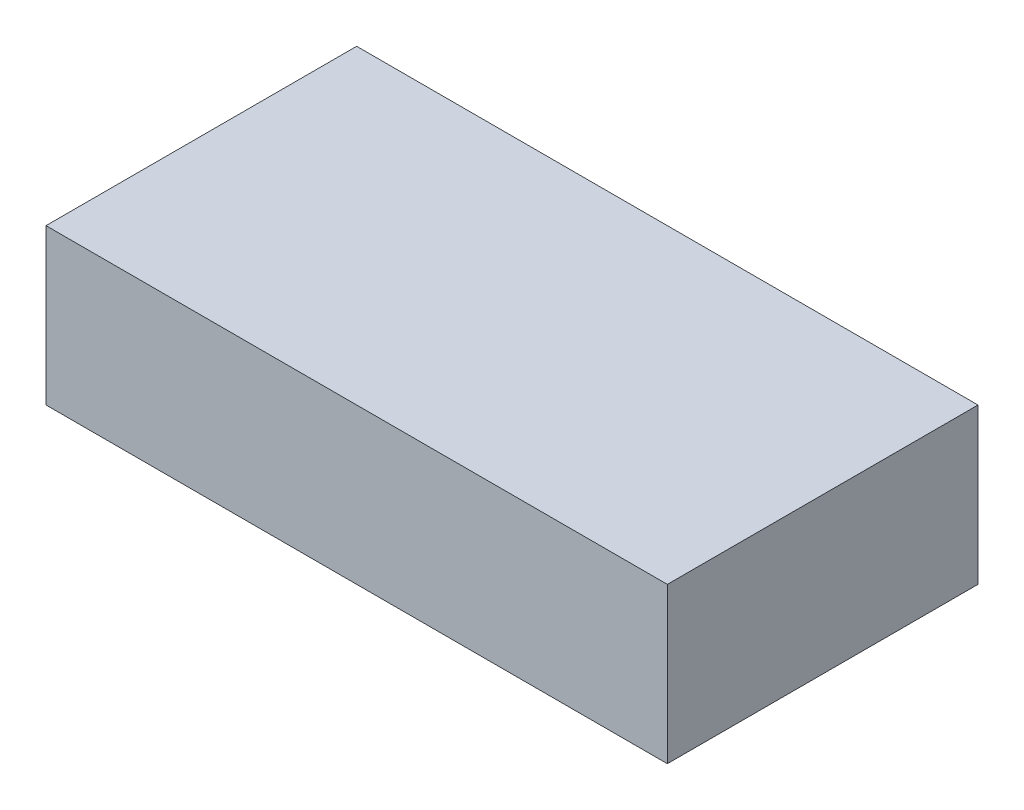
from build123d import *

# Parameters (mm, degrees)
SKETCH1_W           = 200
SKETCH1_H           = 100
BOSS_EXTRUDE1_DEPTH = 25


with BuildPart() as part:
    # Sketch1 → Boss-Extrude1 (new body, symmetric)
    with BuildSketch(Plane(origin=(0, 0, 0), x_dir=(1, 0, 0), z_dir=(0, 1, 0))):
        Rectangle(SKETCH1_W, SKETCH1_H)
    extrude(amount=BOSS_EXTRUDE1_DEPTH, both=True)


solid = part.part
